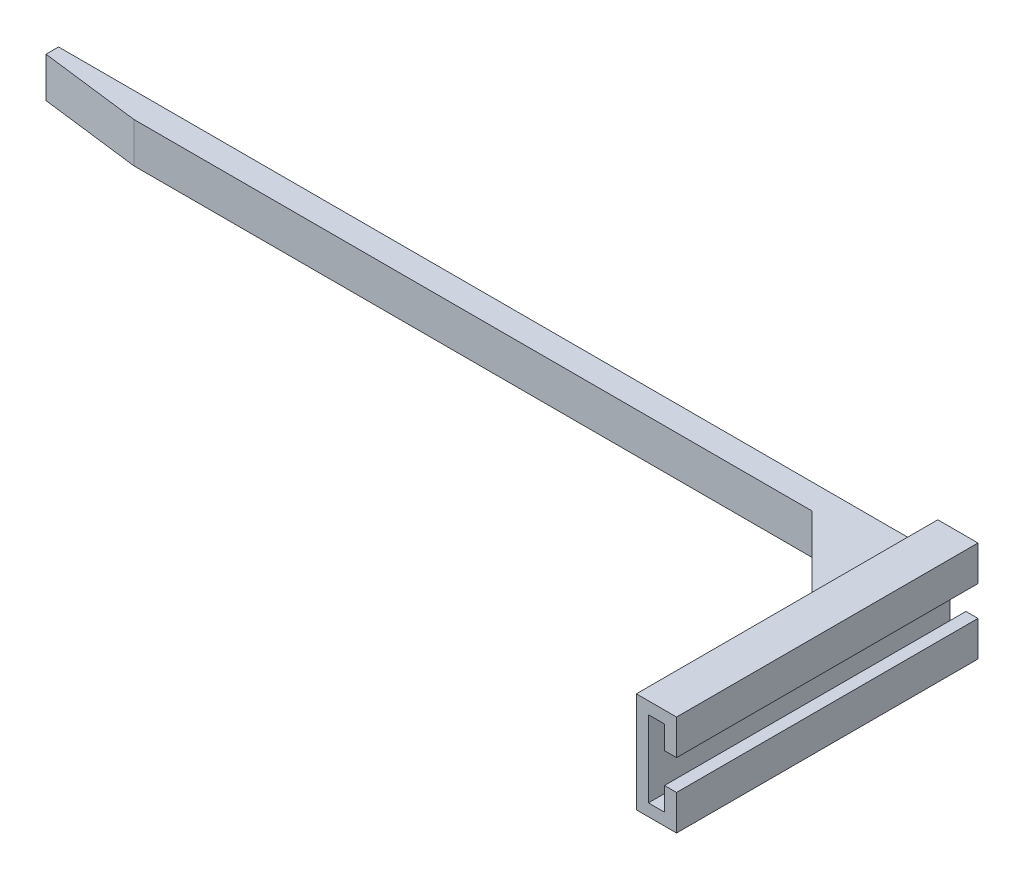
from build123d import *

# Parameters (mm, degrees)
EXTRUDE_1_DEPTH     = 60
SKETCH_2_W          = 5
SKETCH_2_H          = 8
EXTRUDE_2_DEPTH     = 175
CHAMFER_1_SIZE      = 20
CUT_EXTRUDE_1_DEPTH = 33.8
CHAMFER_2_SIZE      = 2


with BuildPart() as part:
    # 草图1 → 凸台-拉伸1 (new body)
    with BuildSketch(Plane.XY):
        Polygon((5.6, 10.6), (3.2, 10.6), (3.2, 15.2), (0, 15.2), (0, 0), (3.2, 0), (3.2, 4.6), (5.6, 4.6), (5.6, -2.4), (-2.4, -2.4), (-2.4, 17.6), (5.6, 17.6), align=None)
    extrude(amount=EXTRUDE_1_DEPTH)

    # 草图2 → 凸台-拉伸2 (add)
    with BuildSketch(Plane.ZY.offset(2.4)):
        with Locations((2.5, 7.6)):
            Rectangle(SKETCH_2_W, SKETCH_2_H)
    extrude(amount=EXTRUDE_2_DEPTH)

    # 倒角1
    chamfer_1_edges = [part.edges().sort_by_distance(p)[0] for p in [
        (-2.4, 7.6, 5),
    ]]
    chamfer(chamfer_1_edges, length=CHAMFER_1_SIZE)

    # 草图3 → 切除-拉伸1 (cut)
    with BuildSketch(Plane(origin=(0, 11.6, 0), x_dir=(1, 0, 0), z_dir=(0, 1, 0))):
        Polygon((-177.4, -2.5), (-157.4, -5), (-177.4, -5), align=None)
    extrude(amount=-CUT_EXTRUDE_1_DEPTH, mode=Mode.SUBTRACT)

    # 倒角2
    chamfer_2_edges = [part.edges().sort_by_distance(p)[0] for p in [
        (-2.4, 3.6, 12.5),
        (-2.4, 11.6, 12.5),
    ]]
    chamfer(chamfer_2_edges, length=CHAMFER_2_SIZE)


solid = part.part
